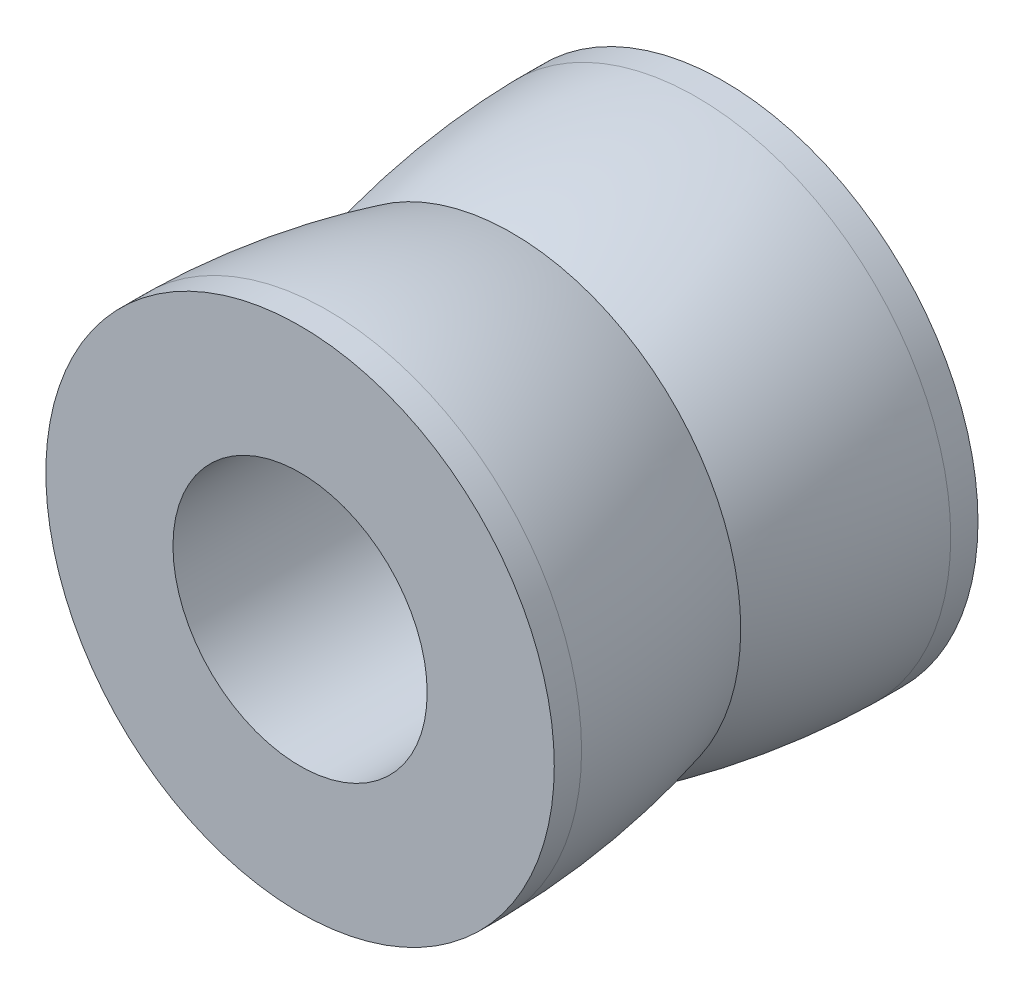
from build123d import *

# Parameters (mm, degrees)
IZIM1_R                     = 6
IZIM1_R_2                   = 3
Y_KSEKLIK_EKSTR_ZYON1_DEPTH = 10


with BuildPart() as part:
    # Çizim1 → Yükseklik-Ekstrüzyon1 (new body)
    with BuildSketch(Plane.XY):
        Circle(IZIM1_R)
        Circle(IZIM1_R_2, mode=Mode.SUBTRACT)
    extrude(amount=Y_KSEKLIK_EKSTR_ZYON1_DEPTH)

    # Çizim2 → Kes-Döndür1 (revolve, cut)
    with BuildSketch(Plane(origin=(0, 0, 0), x_dir=(1, 0, 0), z_dir=(0, 1, 0)), mode=Mode.PRIVATE) as kes_d_nd_r1_sk:
        with BuildLine():
            ThreePointArc((-5.4, -5), (-5.830212785, -2.839937738), (-6, -0.644004152))
            Line((-6, -0.644004152), (-6, -9.355995848))
            ThreePointArc((-6, -9.355995848), (-5.830212785, -7.160062262), (-5.4, -5))
        make_face()
    revolve(kes_d_nd_r1_sk.sketch.rotate(Axis((0, 0, 10), (0, 0, -1)), 180), axis=Axis((0, 0, 10), (0, 0, -1)), mode=Mode.SUBTRACT)


solid = part.part
